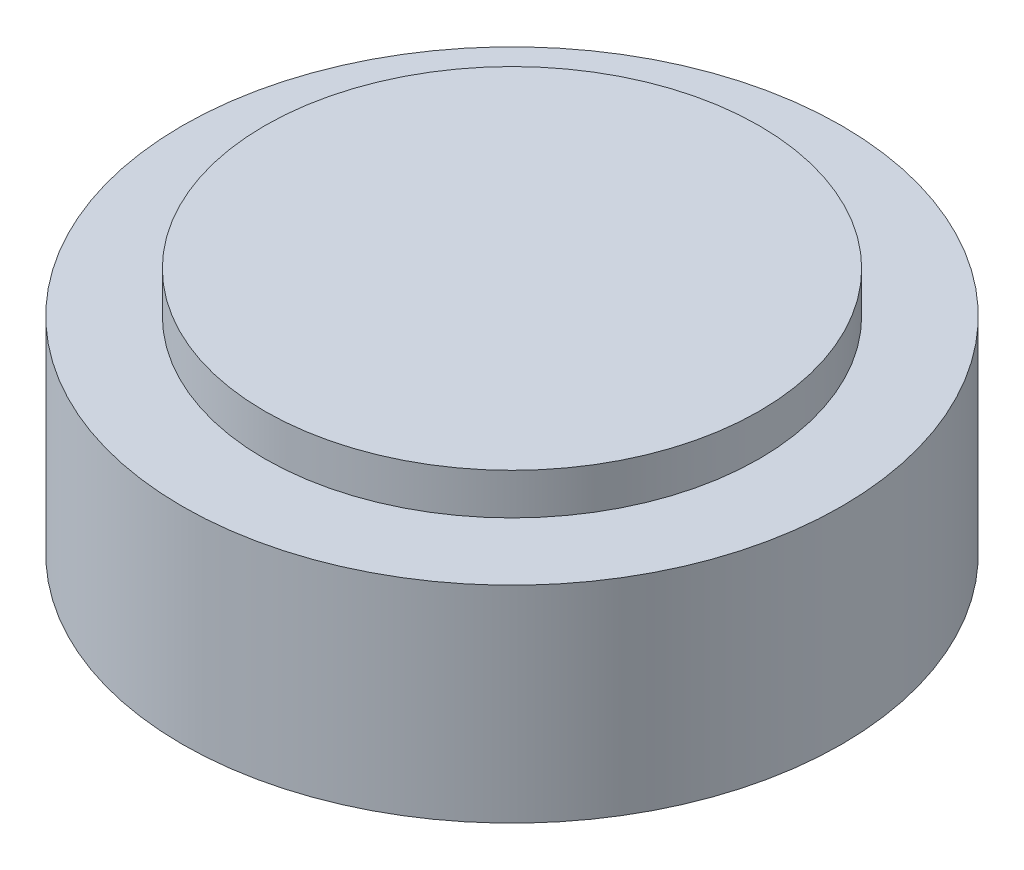
from build123d import *

# Parameters (mm, degrees)
SKETCH2_R          = 14
CUT_EXTRUDE1_DEPTH = 17


with BuildPart() as part:
    # Sketch1 → Revolve1 (revolve)
    with BuildSketch(Plane.XY):
        Polygon((0, 0), (0, 30), (30, 30), (30, 25), (40, 25), (40, 0), align=None)
    revolve(axis=Axis((0, 0, 0), (0, 1, 0)))

    # Sketch2 → Cut-Extrude1 (cut)
    with BuildSketch(Plane.XZ):
        Circle(SKETCH2_R)
    extrude(amount=-CUT_EXTRUDE1_DEPTH, mode=Mode.SUBTRACT)


solid = part.part
